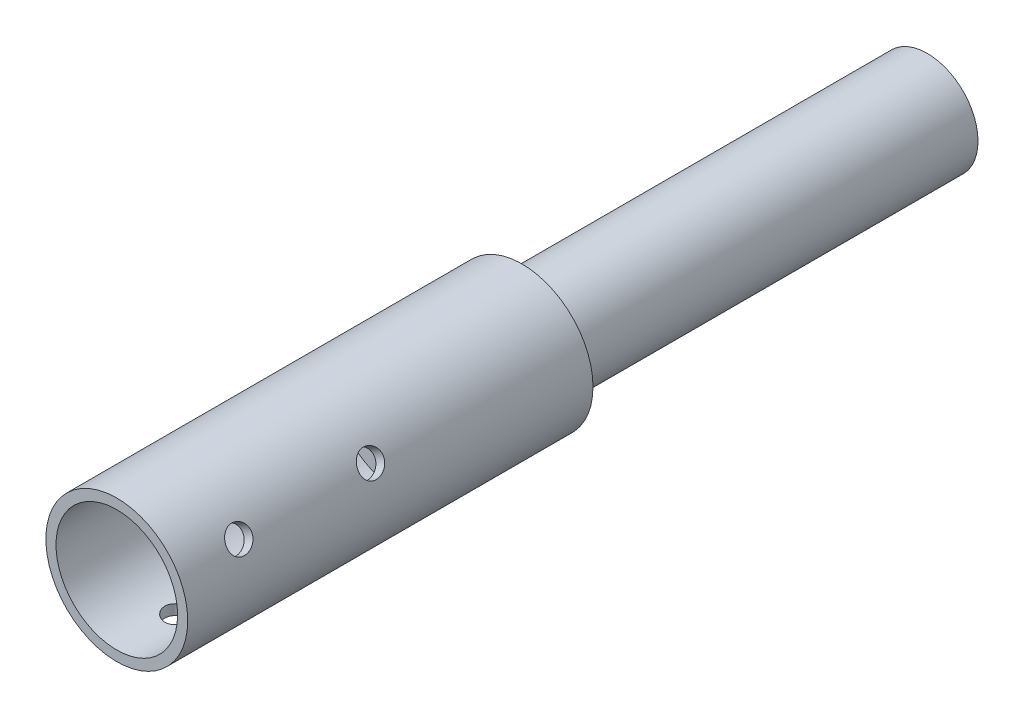
from build123d import *

# Parameters (mm, degrees)
CROQUIS2_R            = 2.5
CORTAR_EXTRUIR1_DEPTH = 15
MATRIZC1_COUNT        = 3


with BuildPart() as part:
    # Croquis1 → Revolución1 (revolve)
    with BuildSketch(Plane(origin=(0, 0, 0), x_dir=(0, 0, -1), z_dir=(1, 0, 0))):
        Polygon((-95, 14), (-95, 12), (-40, 12), (-40, 0), (65, 0), (65, 10), (-15, 10), (-15, 14), align=None)
    revolve(axis=Axis((0, 0, 144.04817275), (0, 0, -1)))

    # Croquis2 → Cortar-Extruir1 (cut)
    with BuildSketch(Plane(origin=(0, 0, 0), x_dir=(1, 0, 0), z_dir=(0, 1, 0))):
        with Locations((0, -83)):
            Circle(CROQUIS2_R)
        with Locations((0, -57)):
            Circle(CROQUIS2_R)
    cortar_extruir1 = extrude(amount=-CORTAR_EXTRUIR1_DEPTH, mode=Mode.SUBTRACT)

    # MatrizC1: Cortar-Extruir1 ×3 about axis
    matrizc1_axis = Axis((0, 0, 103), (0, 0, -1))
    for i in range(1, MATRIZC1_COUNT):
        add(cortar_extruir1.rotate(matrizc1_axis, i * 360 / MATRIZC1_COUNT), mode=Mode.SUBTRACT)


solid = part.part
